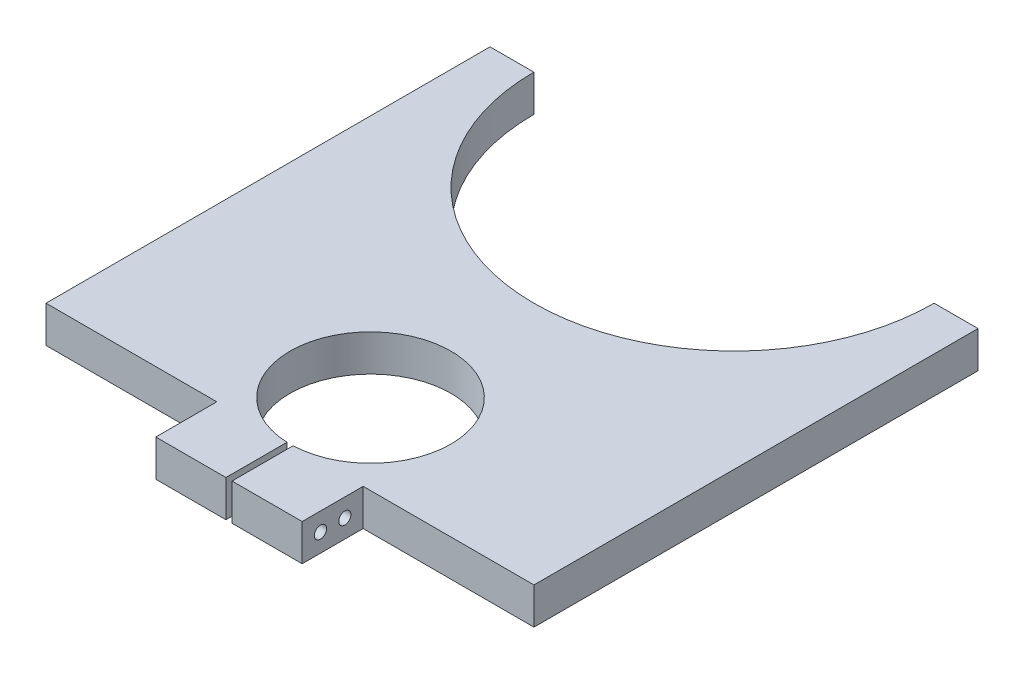
from build123d import *

# Parameters (mm, degrees)
SKETCH1_W           = 127
SKETCH1_H           = 131.445
BOSS_EXTRUDE1_DEPTH = 9.525
SKETCH2_W           = 44.45
SKETCH2_H           = 15.875
CUT_EXTRUDE1_DEPTH  = 10.525
CUT_EXTRUDE2_DEPTH  = 10.525
CUT_EXTRUDE3_DEPTH  = 10.525
SKETCH6_R           = 1.5875
CUT_EXTRUDE4_DEPTH  = 83.55


with BuildPart() as part:
    # Sketch1 → Boss-Extrude1 (new body)
    with BuildSketch(Plane(origin=(0, 0, 0), x_dir=(1, 0, 0), z_dir=(0, 1, 0))):
        with Locations((63.5, -65.7225)):
            Rectangle(SKETCH1_W, SKETCH1_H)
    extrude(amount=BOSS_EXTRUDE1_DEPTH)

    # Sketch2 → Cut-Extrude1 (cut, through all)
    with BuildSketch(Plane(origin=(0, 9.525, 0), x_dir=(1, 0, 0), z_dir=(0, 1, 0))):
        with Locations((22.225, -123.5075)):
            Rectangle(SKETCH2_W, SKETCH2_H)
        with Locations((104.775, -123.5075)):
            Rectangle(SKETCH2_W, SKETCH2_H)
    extrude(amount=-CUT_EXTRUDE1_DEPTH, mode=Mode.SUBTRACT)

    # Sketch3 → Cut-Extrude2 (cut, through all)
    with BuildSketch(Plane(origin=(0, 9.525, 0), x_dir=(1, 0, 0), z_dir=(0, 1, 0))):
        with BuildLine():
            Line((63.5, -131.445), (64.29375, -131.445))
            Line((64.29375, -131.445), (64.29375, -115.57))
            Line((64.29375, -115.57), (64.29375, -115.55496146))
            ThreePointArc((64.29375, -115.55496146), (63.5, -73.66), (62.70625, -115.55496146))
            Line((62.70625, -115.55496146), (62.70625, -115.57))
            Line((62.70625, -115.57), (62.70625, -131.445))
            Line((62.70625, -131.445), (63.5, -131.445))
        make_face()
    extrude(amount=-CUT_EXTRUDE2_DEPTH, mode=Mode.SUBTRACT)

    # Sketch5 → Cut-Extrude3 (cut, through all)
    with BuildSketch(Plane(origin=(0, 9.525, 0), x_dir=(1, 0, 0), z_dir=(0, 1, 0))):
        with BuildLine():
            ThreePointArc((11.41476, 0), (63.5, -52.08524), (115.58524, 0))
            Line((115.58524, 0), (11.41476, 0))
        make_face()
        with BuildLine():
            Line((11.41476, 0), (115.58524, 0))
            ThreePointArc((115.58524, 0), (63.5, 52.08524), (11.41476, 0))
        make_face()
    extrude(amount=-CUT_EXTRUDE3_DEPTH, mode=Mode.SUBTRACT)

    # Sketch6 → Cut-Extrude4 (cut, through all)
    with BuildSketch(Plane.ZY.offset(-44.45)):
        with Locations((120.3325, 4.7625)):
            Circle(SKETCH6_R)
        with Locations((126.6825, 4.7625)):
            Circle(SKETCH6_R)
    extrude(amount=-CUT_EXTRUDE4_DEPTH, mode=Mode.SUBTRACT)


solid = part.part
